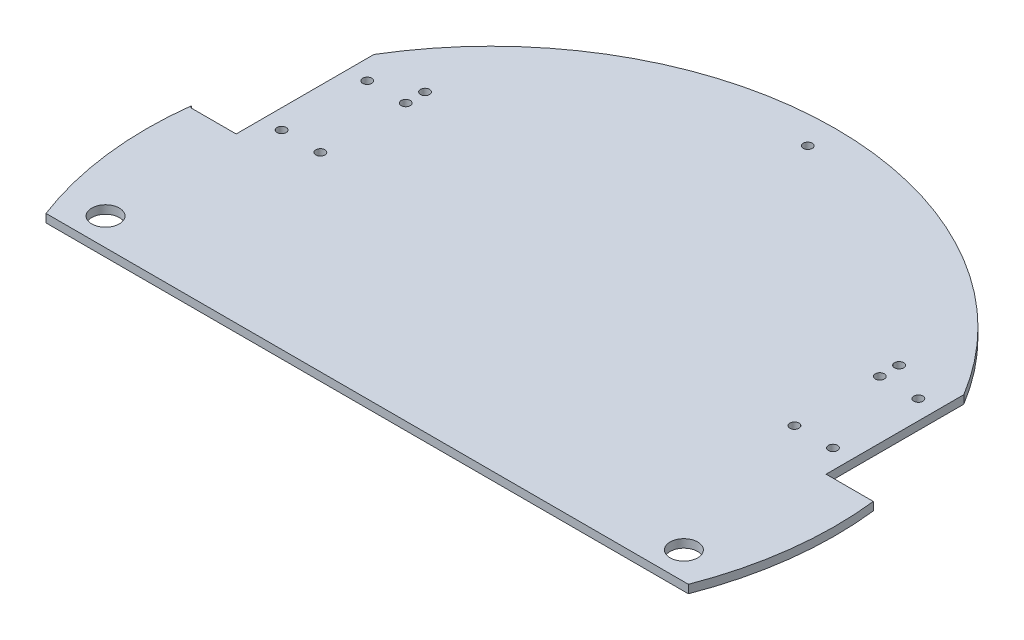
from build123d import *

# Parameters (mm, degrees)
SKETCH2_R           = 125
BOSS_EXTRUDE1_DEPTH = 3
CUT_EXTRUDE1_DEPTH  = 3
SKETCH4_R           = 1.65
SKETCH4_R_2         = 5
CUT_EXTRUDE2_DEPTH  = 10
SKETCH6_R           = 1.65
CUT_EXTRUDE3_DEPTH  = 100


with BuildPart() as part:
    # Sketch2 → Boss-Extrude1 (new body)
    with BuildSketch(Plane(origin=(0, 0, 0), x_dir=(1, 0, 0), z_dir=(0, 1, 0))):
        with Locations((-17.80765369, -0.854894607)):
            Circle(SKETCH2_R)
    extrude(amount=BOSS_EXTRUDE1_DEPTH)

    # Sketch3 → Cut-Extrude1 (cut)
    with BuildSketch(Plane.XZ):
        Polygon((-735.289651923, 45.854894607), (-134.426691587, 45.854894607), (98.811384207, 45.854894607), (699.674344543, 45.854894607), (699.674344543, 1247.580815278), (-735.289651923, 1247.580815278), align=None)
    extrude(amount=-CUT_EXTRUDE1_DEPTH, mode=Mode.SUBTRACT)

    # Sketch4 → Cut-Extrude2 (cut)
    with BuildSketch(Plane(origin=(0, 0, 0), x_dir=(-1, 0, 0), z_dir=(0, -1, 0))):
        with Locations((117.80765369, 54.145105393)):
            Circle(SKETCH4_R)
        with Locations((117.881226527, 23.145192699)):
            Circle(SKETCH4_R)
        with Locations((103.80765369, 54.145105393)):
            Circle(SKETCH4_R)
        with Locations((103.80765369, 23.145105393)):
            Circle(SKETCH4_R)
        with Locations((-68.19234631, 54.267083079)):
            Circle(SKETCH4_R)
        with Locations((-82.19234631, 54.267083079)):
            Circle(SKETCH4_R)
        with Locations((-82.19234631, 23.267083079)):
            Circle(SKETCH4_R)
        with Locations((-68.19234631, 23.267083079)):
            Circle(SKETCH4_R)
        with Locations((122.80765369, -35.854894607)):
            Circle(SKETCH4_R_2)
        with Locations((-87.19234631, -35.854894607)):
            Circle(SKETCH4_R_2)
        Polygon((124.881226527, 63.645105393), (124.881226527, 13.645105393), (141.357501756, 13.645105393), (159.377606719, 40.481299306), align=None)
        Polygon((-89.19234631, 63.767083079), (-89.19234631, 13.767083079), (-106.334191667, 13.767083079), (-114.079843912, 54.596315864), align=None)
    extrude(amount=-CUT_EXTRUDE2_DEPTH, mode=Mode.SUBTRACT)

    # Sketch6 → Cut-Extrude3 (cut)
    with BuildSketch(Plane(origin=(0, 0, 0), x_dir=(-1, 0, 0), z_dir=(0, -1, 0))):
        with Locations((103.80765369, 61.145105393)):
            Circle(SKETCH6_R)
        with Locations((-68.19234631, 61.267083079)):
            Circle(SKETCH6_R)
        with Locations((17.381226527, 113.706374405)):
            Circle(SKETCH6_R)
    extrude(amount=-CUT_EXTRUDE3_DEPTH, mode=Mode.SUBTRACT)


solid = part.part
